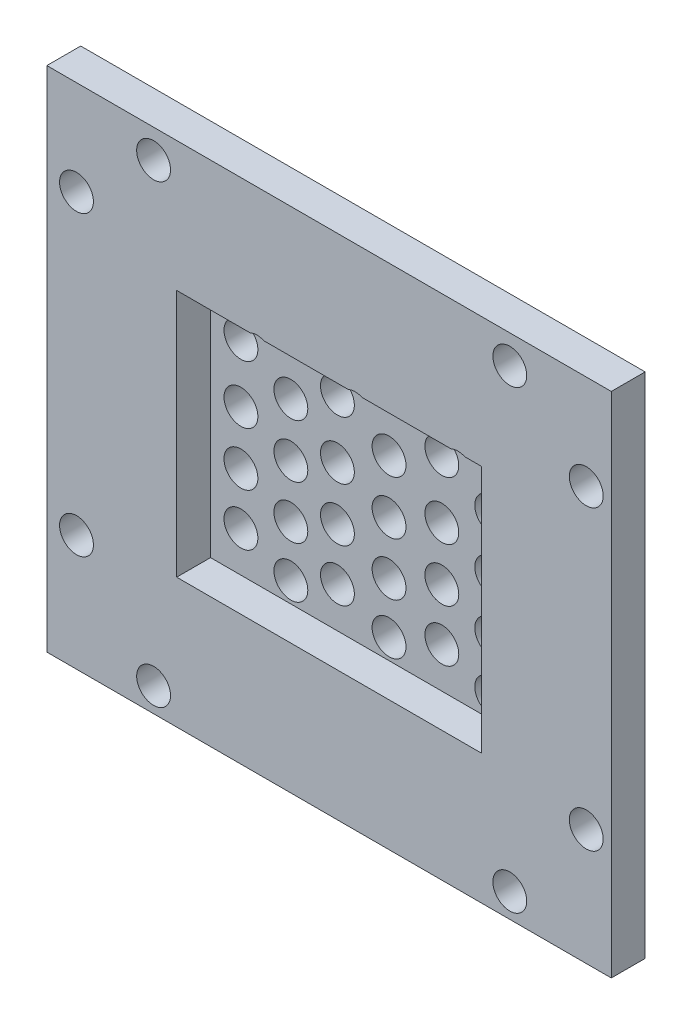
from build123d import *

# Parameters (mm, degrees)
SKETCH1_W             = 50
SKETCH1_H             = 45
BOSS_EXTRUDE1_DEPTH   = 6
SKETCH2_W             = 40
SKETCH2_H             = 35
SKETCH2_W_2           = 30
SKETCH2_H_2           = 26.25
CUT_EXTRUDE1_DEPTH    = 5
SKETCH8_W             = 27
SKETCH8_H             = 22
CUT_EXTRUDE2_DEPTH    = 3
SKETCH19_W            = 50
SKETCH19_H            = 45
SKETCH19_W_2          = 40
SKETCH19_H_2          = 35
CUT_EXTRUDE3_DEPTH    = 3
F_3_0MM_DOWEL_HOLE1_D = 3
F_3_0MM_DOWEL_HOLE2_D = 3


with BuildPart() as part:
    # Sketch1 → Boss-Extrude1 (new body)
    with BuildSketch(Plane.XY):
        Rectangle(SKETCH1_W, SKETCH1_H)
    extrude(amount=BOSS_EXTRUDE1_DEPTH)

    # Sketch2 → Cut-Extrude1 (cut)
    with BuildSketch(Plane(origin=(0, 0, 0), x_dir=(-1, 0, 0), z_dir=(0, 0, -1))):
        Rectangle(SKETCH2_W, SKETCH2_H)
        Rectangle(SKETCH2_W_2, SKETCH2_H_2, mode=Mode.SUBTRACT)
    extrude(amount=-CUT_EXTRUDE1_DEPTH, mode=Mode.SUBTRACT)

    # Sketch8 → Cut-Extrude2 (cut)
    with BuildSketch(Plane.XY.offset(6)):
        Rectangle(SKETCH8_W, SKETCH8_H)
    extrude(amount=-CUT_EXTRUDE2_DEPTH, mode=Mode.SUBTRACT)

    # Sketch19 → Cut-Extrude3 (cut)
    with BuildSketch(Plane(origin=(0, 0, 0), x_dir=(-1, 0, 0), z_dir=(0, 0, -1))):
        Rectangle(SKETCH19_W, SKETCH19_H)
        Rectangle(SKETCH19_W_2, SKETCH19_H_2, mode=Mode.SUBTRACT)
    extrude(amount=-CUT_EXTRUDE3_DEPTH, mode=Mode.SUBTRACT)

    # Ø3.0mm Dowel Hole1 (through all)
    with Locations(Plane(origin=(0, 0, 3), x_dir=(-1, 0, 0), z_dir=(0, 0, -1))):
        with Locations((-22.783121204, 14.123618146), (-22.783121204, -12.211210761), (-16.010997548, -20.358306406), (15.544462002, -20.358306406), (22.374348981, -12.211210761), (22.374348981, 14.123618146), (15.544462002, 19.971474687), (-16.010997548, 19.971474687)):
            Hole(F_3_0MM_DOWEL_HOLE1_D / 2)

    # Ø3.0mm Dowel Hole2 (through all)
    with Locations(Plane(origin=(0, 0, 0), x_dir=(-1, 0, 0), z_dir=(0, 0, -1))):
        with Locations((-11.409364772, 9.632100926), (-11.409364772, 4.733470352), (-11.409364772, 0), (-11.409364772, -4.688879244), (-11.409364772, -9.198386141), (-6.988624357, 7.056308434), (-6.988624357, 1.916488502), (-6.988624357, -2.81999563), (-6.988624357, -7.418696963), (-2.314259653, 9.632100926), (-2.314259653, 4.733470352), (2.260389176, 7.056308434), (6.385498081, 9.632100926), (6.385498081, 4.733470352), (10.808353766, 7.056308434), (-2.314259653, 0), (-2.314259653, -4.688879244), (-2.314259653, -9.198386141), (2.260389176, 1.916488502), (2.260389176, -2.81999563), (2.260389176, -7.418696963), (6.385498081, 0), (6.385498081, -4.688879244), (6.385498081, -9.198386141), (10.808353766, 1.916488502), (10.808353766, -2.81999563), (10.808353766, -7.418696963)):
            Hole(F_3_0MM_DOWEL_HOLE2_D / 2)


solid = part.part
